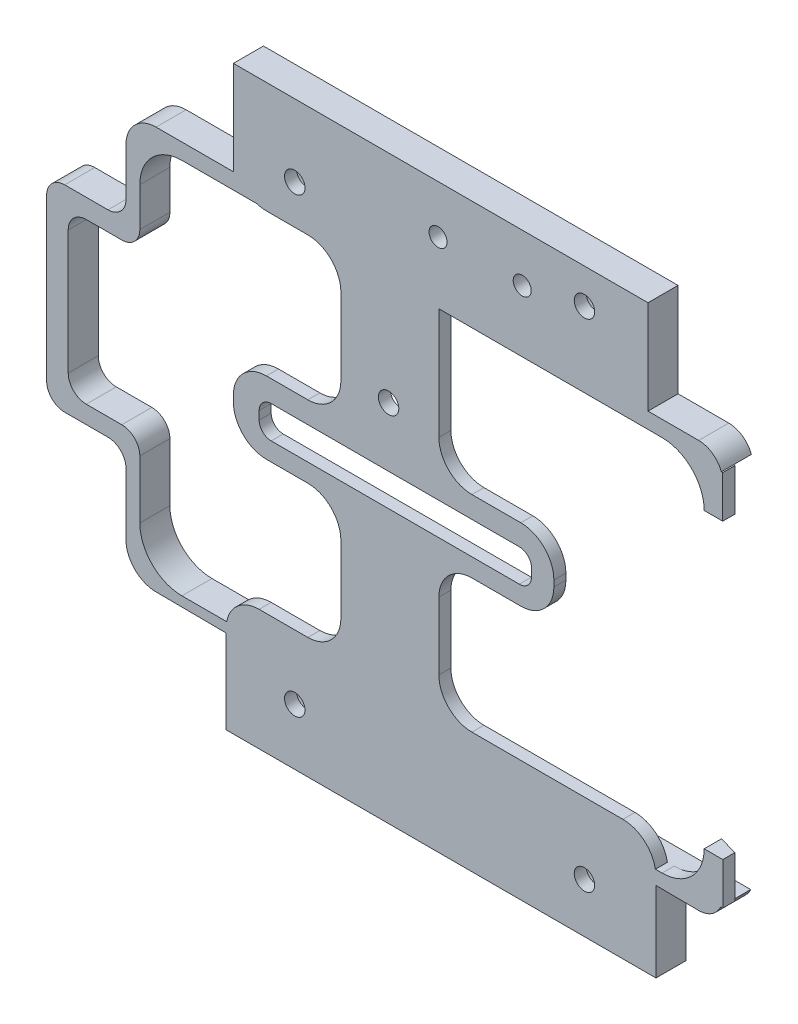
from build123d import *

# Parameters (mm, degrees)
ESQUISSE1_R             = 1.7
BOSS_EXTRU_1_DEPTH      = 3
BOSS_EXTRU_2_DEPTH      = 3
BOSS_EXTRU_2_DEPTH_BACK = 3
ESQUISSE2_R             = 5.2
ESQUISSE5_W             = 129.390100882
ESQUISSE5_H             = 110.068207502
ENL_V_MAT_EXTRU_2_DEPTH = 1
ESQUISSE6_R             = 1.5
ENL_V_MAT_EXTRU_3_DEPTH = 8
ESQUISSE7_W             = 14.610679854
ESQUISSE7_H             = 62.75
ENL_V_MAT_EXTRU_4_DEPTH = 8
BOSS_EXTRU_3_DEPTH      = 7
BOSS_EXTRU_4_DEPTH      = 7


with BuildPart() as part:
    # Esquisse1 → Boss.-Extru.1 (new body)
    with BuildSketch(Plane.XY):
        with BuildLine():
            Line((-117.680084405, 66.939310237), (-117.680084405, 59.695120061))
            ThreePointArc((-117.680084405, 59.695120061), (-116.069171702, 55.806032765), (-112.180084405, 54.195120061))
            Line((-112.180084405, 54.195120061), (-105.294175096, 54.195120061))
            ThreePointArc((-105.294175096, 54.195120061), (-101.4050878, 52.584207358), (-99.794175096, 48.695120061))
            Line((-99.794175096, 48.695120061), (-99.794175096, 35.930823665))
            ThreePointArc((-99.794175096, 35.930823665), (-101.4050878, 32.041736368), (-105.294175096, 30.430823665))
            Line((-105.294175096, 30.430823665), (-112.180084405, 30.430823665))
            ThreePointArc((-112.180084405, 30.430823665), (-116.069171702, 28.819910961), (-117.680084405, 24.930823665))
            Line((-117.680084405, 24.930823665), (-117.680084405, 23.910007682))
            ThreePointArc((-117.680084405, 23.910007682), (-116.069171702, 20.020920385), (-112.180084405, 18.410007682))
            Line((-112.180084405, 18.410007682), (-105.294175096, 18.410007682))
            ThreePointArc((-105.294175096, 18.410007682), (-101.4050878, 16.799094979), (-99.794175096, 12.910007682))
            Line((-99.794175096, 12.910007682), (-99.794175096, 1.692208933))
            ThreePointArc((-99.794175096, 1.692208933), (-101.4050878, -2.196878364), (-105.294175096, -3.807791067))
            Line((-105.294175096, -3.807791067), (-113.390601299, -3.807791067))
            ThreePointArc((-113.390601299, -3.807791067), (-117.279688595, -5.418703771), (-118.890601299, -9.307791067))
            Line((-118.890601299, -9.307791067), (-118.890601299, -18.42196685))
            ThreePointArc((-118.890601299, -18.42196685), (-117.279688595, -22.311054147), (-113.390601299, -23.92196685))
            Line((-113.390601299, -23.92196685), (-52.866544484, -23.92196685))
            ThreePointArc((-52.866544484, -23.92196685), (-48.977457187, -22.311054147), (-47.366544484, -18.42196685))
            Line((-47.366544484, -18.42196685), (-47.366544484, -9.307791067))
            ThreePointArc((-47.366544484, -9.307791067), (-48.977457187, -5.418703771), (-52.866544484, -3.807791067))
            Line((-52.866544484, -3.807791067), (-77.986378892, -3.807791067))
            ThreePointArc((-77.986378892, -3.807791067), (-81.875466189, -2.196878364), (-83.486378892, 1.692208933))
            Line((-83.486378892, 1.692208933), (-83.486378892, 12.910007682))
            ThreePointArc((-83.486378892, 12.910007682), (-81.875466189, 16.799094979), (-77.986378892, 18.410007682))
            Line((-77.986378892, 18.410007682), (-69.856378892, 18.410007682))
            ThreePointArc((-69.856378892, 18.410007682), (-65.967291596, 20.020920385), (-64.356378892, 23.910007682))
            Line((-64.356378892, 23.910007682), (-64.356378892, 24.930823665))
            ThreePointArc((-64.356378892, 24.930823665), (-65.967291596, 28.819910961), (-69.856378892, 30.430823665))
            Line((-69.856378892, 30.430823665), (-77.986378892, 30.430823665))
            ThreePointArc((-77.986378892, 30.430823665), (-81.875466189, 32.041736368), (-83.486378892, 35.930823665))
            Line((-83.486378892, 35.930823665), (-83.486378892, 55.219310237))
            ThreePointArc((-83.486378892, 55.219310237), (-81.875466189, 59.108397534), (-77.986378892, 60.719310237))
            Line((-77.986378892, 60.719310237), (-54.190366806, 60.719310237))
            ThreePointArc((-54.190366806, 60.719310237), (-50.30127951, 62.330222941), (-48.690366806, 66.219310237))
            Line((-48.690366806, 66.219310237), (-48.690366806, 67.219310237))
            ThreePointArc((-48.690366806, 67.219310237), (-50.30127951, 71.108397534), (-54.190366806, 72.719310237))
            Line((-54.190366806, 72.719310237), (-112.180084405, 72.719310237))
            ThreePointArc((-112.180084405, 72.719310237), (-116.069171702, 71.108397534), (-117.680084405, 67.219310237))
            Line((-117.680084405, 67.219310237), (-117.680084405, 66.939310237))
        make_face()
        with Locations((-59.266378892, -15.663707737)):
            Circle(ESQUISSE1_R, mode=Mode.SUBTRACT)
        with Locations((-59.266378892, 66.939310237)):
            Circle(ESQUISSE1_R, mode=Mode.SUBTRACT)
        with Locations((-91.856378892, 36.719310237)):
            Circle(ESQUISSE1_R, mode=Mode.SUBTRACT)
        with Locations((-107.466378892, -14.520689763)):
            Circle(ESQUISSE1_R, mode=Mode.SUBTRACT)
        with Locations((-107.466378892, 60.719310237)):
            Circle(ESQUISSE1_R, mode=Mode.SUBTRACT)
        with BuildLine():
            Line((-111.390601299, 21.460065469), (-70.086378892, 21.460065469))
            ThreePointArc((-70.086378892, 21.460065469), (-68.67216533, 22.045851906), (-68.086378892, 23.460065469))
            Line((-68.086378892, 23.460065469), (-68.086378892, 24.842520386))
            ThreePointArc((-68.086378892, 24.842520386), (-68.67216533, 26.256733949), (-70.086378892, 26.842520386))
            Line((-70.086378892, 26.842520386), (-111.390601299, 26.842520386))
            ThreePointArc((-111.390601299, 26.842520386), (-112.804814861, 26.256733949), (-113.390601299, 24.842520386))
            Line((-113.390601299, 24.842520386), (-113.390601299, 23.460065469))
            ThreePointArc((-113.390601299, 23.460065469), (-112.804814861, 22.045851906), (-111.390601299, 21.460065469))
        make_face(mode=Mode.SUBTRACT)
    extrude(amount=BOSS_EXTRU_1_DEPTH)

    # Esquisse2 → Boss.-Extru.2 (add, two sides: drawn at the far end of the back side and taken through both)
    with BuildSketch(Plane(origin=(0, 0, 0), x_dir=(-1, 0, 0), z_dir=(0, 0, -1)).offset(-BOSS_EXTRU_2_DEPTH_BACK)):
        with BuildLine():
            Line((118.890601299, -9.969506719), (130.584615963, -9.880075131))
            ThreePointArc((130.584615963, -9.880075131), (134.095405897, -8.402210456), (135.546378892, -4.880221341))
            Line((135.546378892, -4.880221341), (135.546378892, 5.415623015))
            ThreePointArc((135.546378892, 5.415623015), (136.425058549, 7.536943358), (138.546378892, 8.415623015))
            Line((138.546378892, 8.415623015), (145.752654566, 8.415623015))
            ThreePointArc((145.752654566, 8.415623015), (147.87397491, 9.294302671), (148.752654566, 11.415623015))
            Line((148.752654566, 11.415623015), (148.752654566, 38.179170847))
            ThreePointArc((148.752654566, 38.179170847), (147.87397491, 40.300491191), (145.752654566, 41.179170847))
            Line((145.752654566, 41.179170847), (138.546378892, 41.179170847))
            ThreePointArc((138.546378892, 41.179170847), (136.425058549, 42.057850504), (135.546378892, 44.179170847))
            Line((135.546378892, 44.179170847), (135.546378892, 52.099902349))
            ThreePointArc((135.546378892, 52.099902349), (134.081912798, 55.635436255), (130.546378892, 57.099902349))
            Line((130.546378892, 57.099902349), (117.680084405, 57.099902349))
            Line((117.680084405, 57.099902349), (117.680084405, 72.719310237))
            Line((117.680084405, 72.719310237), (48.690366806, 72.719310237))
            Line((48.690366806, 72.719310237), (48.690366806, 60.719310237))
            Line((48.690366806, 60.719310237), (48.690366806, 57.099902349))
            Line((48.690366806, 57.099902349), (40.256901013, 57.099902349))
            ThreePointArc((40.256901013, 57.099902349), (37.428473888, 55.928329474), (36.256901013, 53.099902349))
            Line((36.256901013, 53.099902349), (36.256901013, 47.456292263))
            Line((36.256901013, 47.456292263), (39.346378892, 47.456292263))
            ThreePointArc((39.346378892, 47.456292263), (41.396631424, 52.406039732), (46.346378892, 54.456292263))
            Line((46.346378892, 54.456292263), (126.246378892, 54.456292263))
            ThreePointArc((126.246378892, 54.456292263), (131.196126361, 52.406039732), (133.246378892, 47.456292263))
            Line((133.246378892, 47.456292263), (133.246378892, 40.977229779))
            ThreePointArc((133.246378892, 40.977229779), (134.125058549, 38.855909436), (136.246378892, 37.977229779))
            Line((136.246378892, 37.977229779), (142.162261637, 37.977229779))
            ThreePointArc((142.162261637, 37.977229779), (144.28358198, 37.098550123), (145.162261637, 34.977229779))
            Line((145.162261637, 34.977229779), (145.162261637, 14.363062522))
            ThreePointArc((145.162261637, 14.363062522), (144.28358198, 12.241742179), (142.162261637, 11.363062522))
            Line((142.162261637, 11.363062522), (136.246378892, 11.363062522))
            ThreePointArc((136.246378892, 11.363062522), (134.125058549, 10.484382866), (133.246378892, 8.363062522))
            Line((133.246378892, 8.363062522), (133.246378892, -1.293707737))
            ThreePointArc((133.246378892, -1.293707737), (131.196126361, -6.243455205), (126.246378892, -8.293707737))
            Line((126.246378892, -8.293707737), (46.346378892, -8.293707737))
            ThreePointArc((46.346378892, -8.293707737), (41.396631424, -6.243455205), (39.346378892, -1.293707737))
            Line((39.346378892, -1.293707737), (36.248203357, -1.293707737))
            Line((36.248203357, -1.293707737), (36.248203357, -6.64542392))
            ThreePointArc((36.248203357, -6.64542392), (37.432020164, -9.486042202), (40.282759469, -10.645274652))
            Line((40.282759469, -10.645274652), (47.366544484, -10.58407535))
            Line((47.366544484, -10.58407535), (47.366544484, -23.92196685))
            Line((47.366544484, -23.92196685), (118.890601299, -23.92196685))
            Line((118.890601299, -23.92196685), (118.890601299, -9.969506719))
        make_face()
        with Locations((59.266378892, -15.663707737)):
            Circle(ESQUISSE2_R, mode=Mode.SUBTRACT)
        with Locations((107.466378892, -14.520689763)):
            Circle(ESQUISSE2_R, mode=Mode.SUBTRACT)
        with Locations((107.466378892, 60.719310237)):
            Circle(ESQUISSE2_R, mode=Mode.SUBTRACT)
        with Locations((59.266378892, 66.939310237)):
            Circle(ESQUISSE2_R, mode=Mode.SUBTRACT)
    extrude(amount=BOSS_EXTRU_2_DEPTH + BOSS_EXTRU_2_DEPTH_BACK)

    # Esquisse5 → Enlèv. mat.-Extru.2 (cut)
    with BuildSketch(Plane.XY.offset(3)):
        with Locations((-91.695706627, 24.836368366)):
            Rectangle(ESQUISSE5_W, ESQUISSE5_H)
    extrude(amount=-ENL_V_MAT_EXTRU_2_DEPTH, mode=Mode.SUBTRACT)

    # Esquisse6 → Enlèv. mat.-Extru.3 (cut)
    with BuildSketch(Plane.XY.offset(2)):
        with Locations((-69.623492164, 64.727424081)):
            Circle(ESQUISSE6_R)
        with Locations((-83.623492164, 64.727424081)):
            Circle(ESQUISSE6_R)
    extrude(amount=-ENL_V_MAT_EXTRU_3_DEPTH, mode=Mode.SUBTRACT)

    # Esquisse7 → Enlèv. mat.-Extru.4 (cut)
    with BuildSketch(Plane(origin=(0, 0, 0), x_dir=(-1, 0, 0), z_dir=(0, 0, -1))):
        with Locations((42.567758063, 23.081292263)):
            Rectangle(ESQUISSE7_W, ESQUISSE7_H)
    extrude(amount=ENL_V_MAT_EXTRU_4_DEPTH, mode=Mode.SUBTRACT)

    # Esquisse9 → Boss.-Extru.3 (add)
    with BuildSketch(Plane(origin=(0, -1.293707737, 0), x_dir=(1, 0, 0), z_dir=(0, 1, 0))):
        Polygon((-39.346378892, -2), (-39.346378892, 0.886005049), (-36.248203357, 0), (-36.248203357, -2), align=None)
    extrude(amount=-BOSS_EXTRU_3_DEPTH)

    # Esquisse10 → Boss.-Extru.4 (add)
    with BuildSketch(Plane.XZ.offset(-47.456292263)):
        Polygon((-39.346378892, 2), (-39.346378892, -0.873043126), (-36.256901013, 0), (-36.256901013, 2), align=None)
    extrude(amount=-BOSS_EXTRU_4_DEPTH)


solid = part.part
